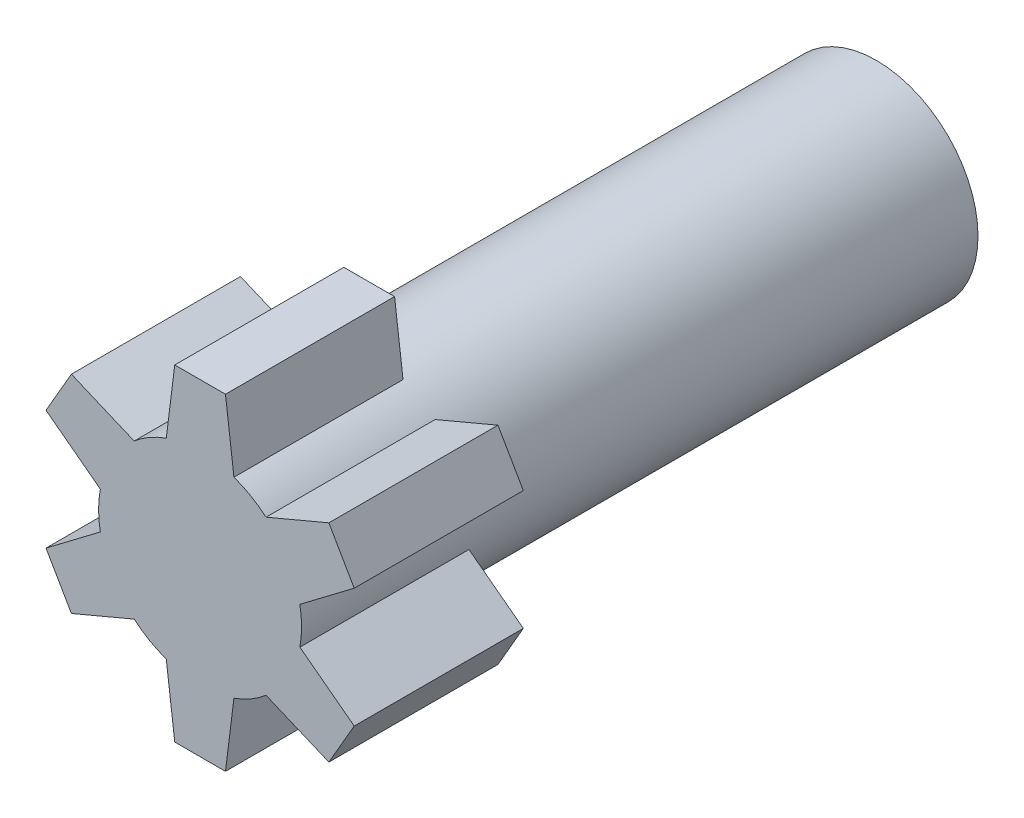
from build123d import *

# Parameters (mm, degrees)
ESQUISSE1_R                  = 3
MAIN_EXTRUSION_DEPTH         = 5
GEAR_ELEMENT_DEPTH           = 5
R_P_TITION_CIRCULAIRE1_COUNT = 6
ESQUISSE3_R                  = 3
MAIN_AXE_DEPTH               = 15
ESQUISSE4_W                  = 4
ESQUISSE4_H                  = 1
AXE_TRAIT_DEPTH              = 3


with BuildPart() as part:
    # Esquisse1 → Main Extrusion (new body)
    with BuildSketch(Plane.XY):
        Circle(ESQUISSE1_R)
    extrude(amount=MAIN_EXTRUSION_DEPTH)

    # Esquisse2 → Gear Element (add)
    with BuildSketch(Plane.XY.offset(5)):
        Polygon((-1, 2.828427125), (1, 2.828427125), (0.75, 4.828427125), (-0.75, 4.828427125), align=None)
    gear_element = extrude(amount=-GEAR_ELEMENT_DEPTH)

    # Répétition circulaire1: Gear Element ×6 about axis
    r_p_tition_circulaire1_axis = Axis((0, 0, 0), (0, 0, 1))
    for i in range(1, R_P_TITION_CIRCULAIRE1_COUNT):
        add(gear_element.rotate(r_p_tition_circulaire1_axis, i * 360 / R_P_TITION_CIRCULAIRE1_COUNT))

    # Esquisse3 → Main Axe (add)
    with BuildSketch(Plane(origin=(0, 0, 0), x_dir=(-1, 0, 0), z_dir=(0, 0, -1))):
        Circle(ESQUISSE3_R)
    extrude(amount=MAIN_AXE_DEPTH)

    # Esquisse4 → Axe Trait (cut)
    with BuildSketch(Plane(origin=(0, 0, -15), x_dir=(-1, 0, 0), z_dir=(0, 0, -1))):
        Rectangle(ESQUISSE4_W, ESQUISSE4_H)
    extrude(amount=-AXE_TRAIT_DEPTH, mode=Mode.SUBTRACT)


solid = part.part
